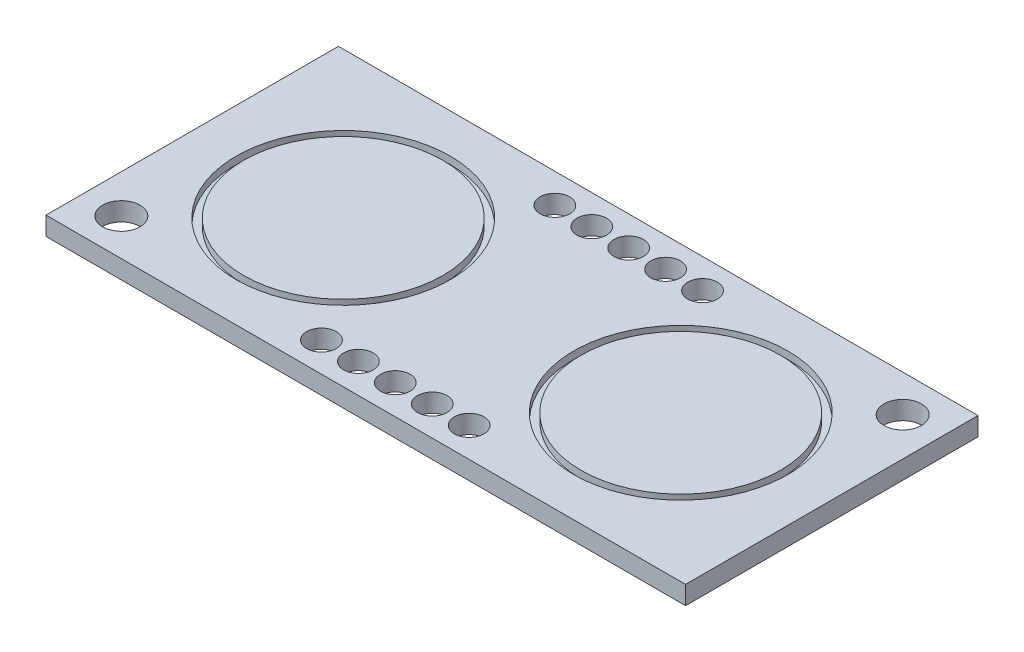
from build123d import *

# Parameters (mm, degrees)
SKETCH1_W      = 43.3
SKETCH1_H      = 19.8
SKETCH1_R      = 1.27
SKETCH1_R_2    = 1
EXTRUDE1_DEPTH = 1.25
SKETCH2_R      = 7.25
SKETCH2_R_2    = 6.75
EXTRUDE2_DEPTH = 0.5


with BuildPart() as part:
    # Sketch1 → Extrude1 (new body)
    with BuildSketch(Plane(origin=(0, 0, 0), x_dir=(1, 0, 0), z_dir=(0, 1, 0))):
        Rectangle(SKETCH1_W, SKETCH1_H)
        with Locations(Location((-19.05, -7.4, 0), (0, 0, 270))):  # turned: the seam where the file's is
            Circle(SKETCH1_R, mode=Mode.SUBTRACT)
        with Locations(Location((19.05, 7.4, 0), (0, 0, 270))):  # turned: the seam where the file's is
            Circle(SKETCH1_R, mode=Mode.SUBTRACT)
        with Locations(Location((0, -7.9, 0), (0, 0, 270))):  # turned: the seam where the file's is
            Circle(SKETCH1_R_2, mode=Mode.SUBTRACT)
        with Locations(Location((0, 7.9, 0), (0, 0, 270))):  # turned: the seam where the file's is
            Circle(SKETCH1_R_2, mode=Mode.SUBTRACT)
        with Locations(Location((2.5, 7.9, 0), (0, 0, 270))):  # turned: the seam where the file's is
            Circle(SKETCH1_R_2, mode=Mode.SUBTRACT)
        with Locations(Location((5, 7.9, 0), (0, 0, 270))):  # turned: the seam where the file's is
            Circle(SKETCH1_R_2, mode=Mode.SUBTRACT)
        with Locations(Location((-2.5, 7.9, 0), (0, 0, 270))):  # turned: the seam where the file's is
            Circle(SKETCH1_R_2, mode=Mode.SUBTRACT)
        with Locations(Location((-5, 7.9, 0), (0, 0, 270))):  # turned: the seam where the file's is
            Circle(SKETCH1_R_2, mode=Mode.SUBTRACT)
        with Locations(Location((-5, -7.9, 0), (0, 0, 270))):  # turned: the seam where the file's is
            Circle(SKETCH1_R_2, mode=Mode.SUBTRACT)
        with Locations(Location((-2.5, -7.9, 0), (0, 0, 270))):  # turned: the seam where the file's is
            Circle(SKETCH1_R_2, mode=Mode.SUBTRACT)
        with Locations(Location((2.5, -7.9, 0), (0, 0, 270))):  # turned: the seam where the file's is
            Circle(SKETCH1_R_2, mode=Mode.SUBTRACT)
        with Locations(Location((5, -7.9, 0), (0, 0, 270))):  # turned: the seam where the file's is
            Circle(SKETCH1_R_2, mode=Mode.SUBTRACT)
    extrude(amount=EXTRUDE1_DEPTH)

    # Sketch2 → Extrude2 (cut)
    with BuildSketch(Plane(origin=(0, 1.25, 0), x_dir=(1, 0, 0), z_dir=(0, 1, 0))):
        with Locations(Location((-11.425, 0, 0), (0, 0, 270))):  # turned: the seam where the file's is
            Circle(SKETCH2_R)
        with Locations(Location((-11.425, 0, 0), (0, 0, 270))):  # turned: the seam where the file's is
            Circle(SKETCH2_R_2, mode=Mode.SUBTRACT)
        with Locations(Location((11.425, 0, 0), (0, 0, 270))):  # turned: the seam where the file's is
            Circle(SKETCH2_R)
        with Locations(Location((11.425, 0, 0), (0, 0, 270))):  # turned: the seam where the file's is
            Circle(SKETCH2_R_2, mode=Mode.SUBTRACT)
    extrude(amount=-EXTRUDE2_DEPTH, mode=Mode.SUBTRACT)


solid = part.part
